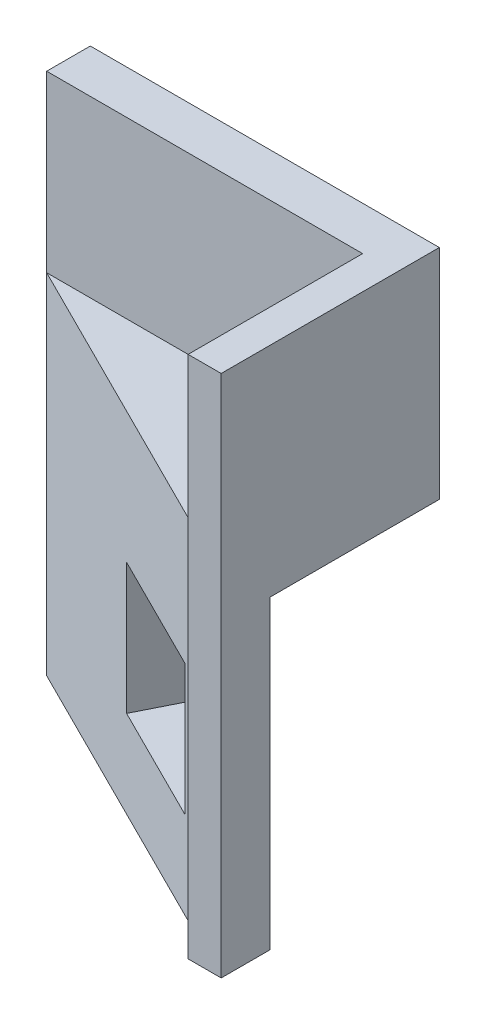
from build123d import *

# Parameters (mm, degrees)
SKETCH1_W           = 50.8
SKETCH1_H           = 76.2
BOSS_EXTRUDE1_DEPTH = 6.35
SKETCH2_W           = 50.8
SKETCH2_H           = 50.8
BOSS_EXTRUDE2_DEPTH = 25.4
CUT_EXTRUDE1_REACH  = 52.8
SKETCH4_W           = 4.813703211
SKETCH4_H           = 76.2
BOSS_EXTRUDE3_DEPTH = 31.75
CUT_EXTRUDE2_DEPTH  = 44.45
CUT_EXTRUDE3_REACH  = 30.398
SKETCH6_W           = 19.05
SKETCH6_H           = 19.05


with BuildPart() as part:
    # Sketch1 → Boss-Extrude1 (new body)
    with BuildSketch(Plane.XY):
        with Locations((25.4, -38.1)):
            Rectangle(SKETCH1_W, SKETCH1_H)
    extrude(amount=BOSS_EXTRUDE1_DEPTH)

    # Sketch2 → Boss-Extrude2 (add)
    with BuildSketch(Plane.XY.offset(6.35)):
        with Locations((25.4, -50.8)):
            Rectangle(SKETCH2_W, SKETCH2_H)
    extrude(amount=BOSS_EXTRUDE2_DEPTH)

    # Sketch3 → Cut-Extrude1 (cut, up to next)
    with BuildSketch(Plane(origin=(0, -25.4, 0), x_dir=(1, 0, 0), z_dir=(0, 1, 0)), mode=Mode.PRIVATE) as cut_extrude1_sk1:
        Polygon((0, -6.35), (0, -31.75), (50.8, -31.75), align=None)
    cut_extrude1_tool1 = extrude(cut_extrude1_sk1.sketch, amount=-CUT_EXTRUDE1_REACH, mode=Mode.PRIVATE) & part.part
    add(cut_extrude1_tool1.solids().sort_by_distance((16.933333, -25.4, 23.283333))[0], mode=Mode.SUBTRACT)

    # Sketch4 → Boss-Extrude3 (add)
    with BuildSketch(Plane(origin=(0, 0, 0), x_dir=(-1, 0, 0), z_dir=(0, 0, -1))):
        with Locations((-48.393148395, -38.1)):
            Rectangle(SKETCH4_W, SKETCH4_H)
    extrude(amount=-BOSS_EXTRUDE3_DEPTH)

    # Sketch5 → Cut-Extrude2 (cut)
    with BuildSketch(Plane.XZ.offset(76.2)):
        Polygon((50.8, 0), (50.8, 24.650484171), (1.499031657, 0), align=None)
    extrude(amount=-CUT_EXTRUDE2_DEPTH, mode=Mode.SUBTRACT)

    # Sketch6 → Cut-Extrude3 (cut, up to next)
    with BuildSketch(Plane(origin=(-2.54, 0, 5.08), x_dir=(0.894427191, 0, 0.447213595), z_dir=(-0.447213595, 0, 0.894427191)), mode=Mode.PRIVATE) as cut_extrude3_sk1:
        with Locations((38.379049159, -53.975)):
            Rectangle(SKETCH6_W, SKETCH6_H)
    cut_extrude3_tool1 = extrude(cut_extrude3_sk1.sketch, amount=-CUT_EXTRUDE3_REACH, mode=Mode.PRIVATE) & part.part
    add(cut_extrude3_tool1.solids().sort_by_distance((31.787265, -53.975, 22.243633))[0], mode=Mode.SUBTRACT)


solid = part.part
